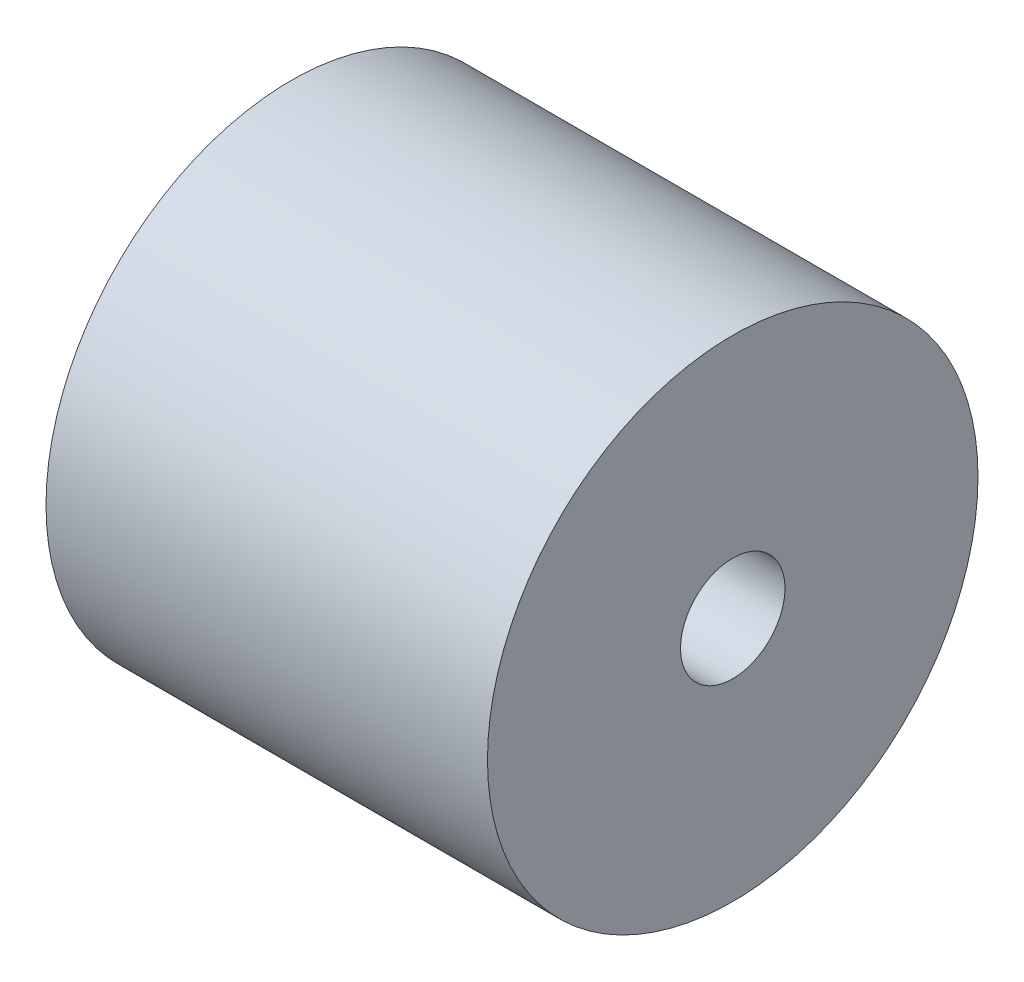
from build123d import *

# Parameters (mm, degrees)
SKETCH1_R             = 6.35
BOSS_EXTRUDE1_DEPTH   = 11.43
F_6_32_TAPPED_HOLE1_D = 2.7051


with BuildPart() as part:
    # Sketch1 → Boss-Extrude1 (new body)
    with BuildSketch(Plane(origin=(0, 0, 0), x_dir=(0, 0, -1), z_dir=(1, 0, 0))):
        Circle(SKETCH1_R)
    extrude(amount=BOSS_EXTRUDE1_DEPTH)

    # #6-32 Tapped Hole1 (through all)
    with Locations(Plane.ZY):
        with Locations((0, 0)):
            Hole(F_6_32_TAPPED_HOLE1_D / 2)


solid = part.part
